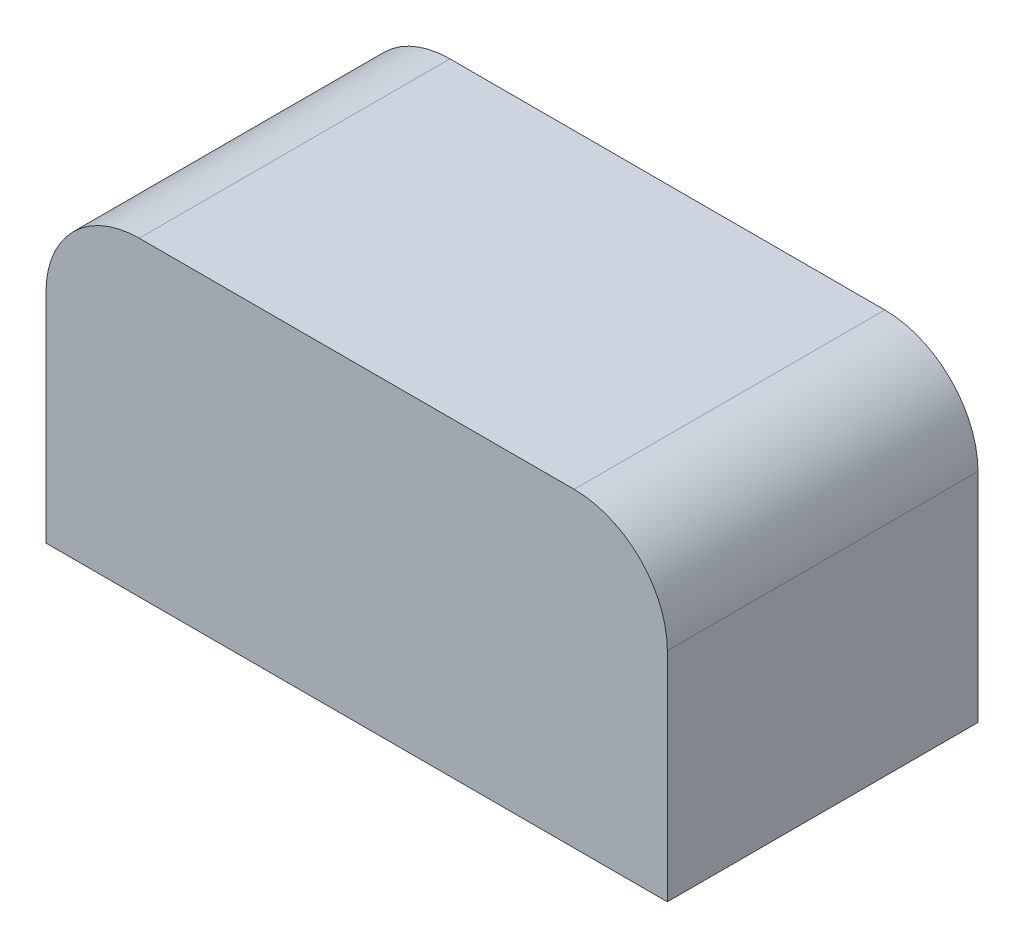
from build123d import *

# Parameters (mm, degrees)
SKETCH1_W           = 20
SKETCH1_H           = 10
BOSS_EXTRUDE1_DEPTH = 10
FILLET1_R           = 3


with BuildPart() as part:
    # Sketch1 → Boss-Extrude1 (new body)
    with BuildSketch(Plane.XY):
        with Locations((-163.021650731, 244.381138351)):
            Rectangle(SKETCH1_W, SKETCH1_H)
    extrude(amount=BOSS_EXTRUDE1_DEPTH)

    # Fillet1
    fillet1_edges = [part.edges().sort_by_distance(p)[0] for p in [
        (-153.021650731, 249.381138351, 5),
        (-173.021650731, 249.381138351, 5),
    ]]
    fillet(fillet1_edges, radius=FILLET1_R)


solid = part.part
